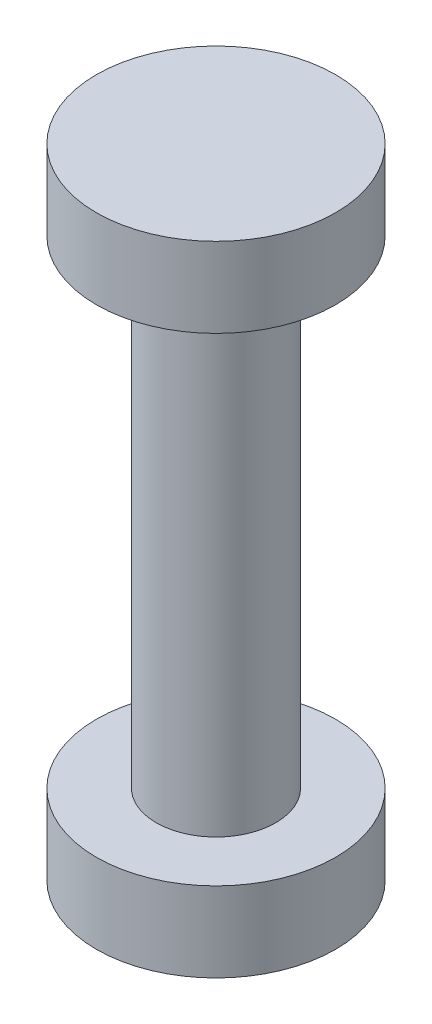
from build123d import *


with BuildPart() as part:
    # Esboço1 → Revolução1 (revolve)
    with BuildSketch(Plane.XY):
        Polygon((0, 8), (3, 8), (3, 6), (1.5, 6), (1.5, -6), (3, -6), (3, -8), (0, -8), align=None)
    revolve(axis=Axis((0, 8, 0), (0, -1, 0)))


solid = part.part
